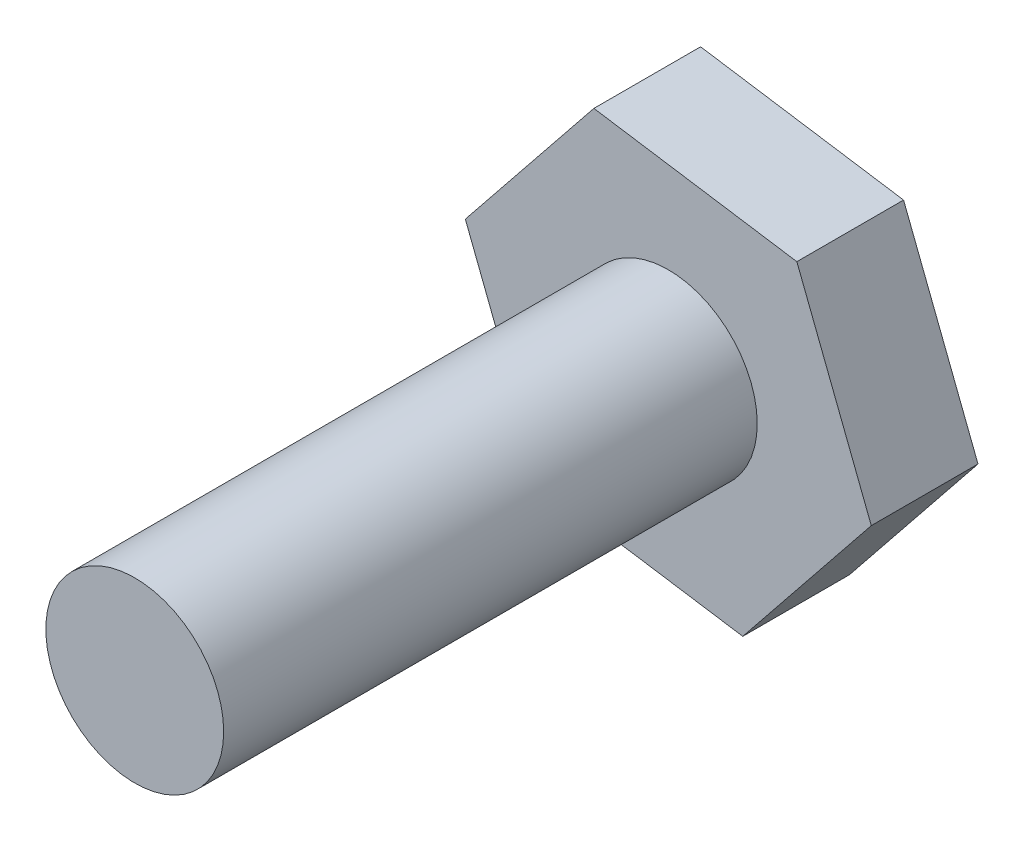
from build123d import *

# Parameters (mm, degrees)
SALIENTE_EXTRUIR3_DEPTH = 3
CROQUIS3_R              = 2.5
SALIENTE_EXTRUIR4_DEPTH = 18


with BuildPart() as part:
    # Croquis1 → Saliente-Extruir3 (new body)
    with BuildSketch(Plane.XY):
        Polygon((-54.386636348, 4.299863782), (-50.772905222, 8.802560828), (-52.865489687, 14.183492308), (-58.571805277, 15.061726742), (-62.185536402, 10.559029696), (-60.092951938, 5.178098216), align=None)
    extrude(amount=SALIENTE_EXTRUIR3_DEPTH)

    # Croquis3 → Saliente-Extruir4 (add)
    with BuildSketch(Plane.XY):
        with Locations((-56.479220812, 9.680795262)):
            Circle(CROQUIS3_R)
    extrude(amount=SALIENTE_EXTRUIR4_DEPTH)


solid = part.part
